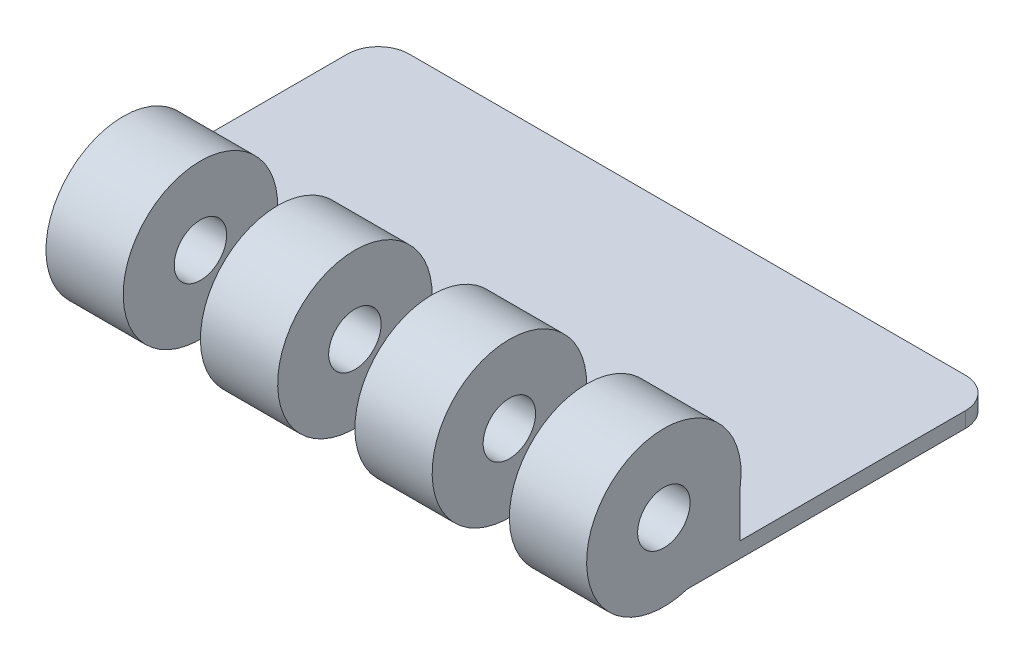
from build123d import *

# Parameters (mm, degrees)
SKETCH1_W           = 50.8
SKETCH1_H           = 25.4
BOSS_EXTRUDE1_DEPTH = 5.08
SKETCH2_R           = 6.35
BOSS_EXTRUDE2_DEPTH = 6.35
LPATTERN1_COUNT     = 4
LPATTERN1_PITCH     = 12.7
SKETCH2_4_R         = 2.15503395
CUT_EXTRUDE2_DEPTH  = 76.2
SKETCH4_W           = 6.35
SKETCH4_H           = 5.08
CUT_EXTRUDE3_DEPTH  = 5.08
CUT_EXTRUDE4_DEPTH  = 3.81
FILLET1_R           = 2.54


with BuildPart() as part:
    # Sketch1 → Boss-Extrude1 (new body)
    with BuildSketch(Plane(origin=(0, 0, 0), x_dir=(1, 0, 0), z_dir=(0, 1, 0))):
        Rectangle(SKETCH1_W, SKETCH1_H)
    extrude(amount=BOSS_EXTRUDE1_DEPTH)

    # Sketch2 → Boss-Extrude2 (add)
    with BuildSketch(Plane(origin=(25.4, 0, 0), x_dir=(0, 0, -1), z_dir=(1, 0, 0))):
        with Locations((-14.623557735, 6.051646523)):
            Circle(SKETCH2_R)
    boss_extrude2 = extrude(amount=-BOSS_EXTRUDE2_DEPTH)

    # LPattern1: Boss-Extrude2 ×4
    with Locations(*[(-i * LPATTERN1_PITCH, 0, 0) for i in range(1, LPATTERN1_COUNT)]):
        add(boss_extrude2)

    # Sketch2_4 → Cut-Extrude2 (cut)
    with BuildSketch(Plane(origin=(25.4, 0, 0), x_dir=(0, 0, -1), z_dir=(1, 0, 0))):
        with Locations((-14.623557735, 6.051646523)):
            Circle(SKETCH2_4_R)
    extrude(amount=-CUT_EXTRUDE2_DEPTH, mode=Mode.SUBTRACT)

    # Sketch4 → Cut-Extrude3 (cut)
    with BuildSketch(Plane.XY.offset(12.7)):
        with Locations((15.875, 2.54)):
            Rectangle(SKETCH4_W, SKETCH4_H)
        with Locations((3.175, 2.54)):
            Rectangle(SKETCH4_W, SKETCH4_H)
        with Locations((-9.525, 2.54)):
            Rectangle(SKETCH4_W, SKETCH4_H)
        with Locations((-22.225, 2.54)):
            Rectangle(SKETCH4_W, SKETCH4_H)
    extrude(amount=-CUT_EXTRUDE3_DEPTH, mode=Mode.SUBTRACT)

    # Sketch5 → Cut-Extrude4 (cut)
    with BuildSketch(Plane(origin=(0, 5.08, 0), x_dir=(1, 0, 0), z_dir=(0, 1, 0))):
        Polygon((12.7, -7.62), (19.05, -7.62), (19.05, -8.348336382), (25.4, -8.348336382), (25.4, 12.7), (-25.4, 12.7), (-25.4, -7.62), (-19.05, -7.62), (-19.05, -8.348336382), (-12.7, -8.348336382), (-12.7, -7.62), (-6.35, -7.62), (-6.35, -8.348336382), (0, -8.348336382), (0, -7.62), (6.35, -7.62), (6.35, -8.348336382), (12.7, -8.348336382), align=None)
    extrude(amount=-CUT_EXTRUDE4_DEPTH, mode=Mode.SUBTRACT)

    # Fillet1
    fillet1_edges = [part.edges().sort_by_distance(p)[0] for p in [
        (25.4, 0.635, -12.7),
        (-25.4, 0.635, -12.7),
    ]]
    fillet(fillet1_edges, radius=FILLET1_R)


solid = part.part
